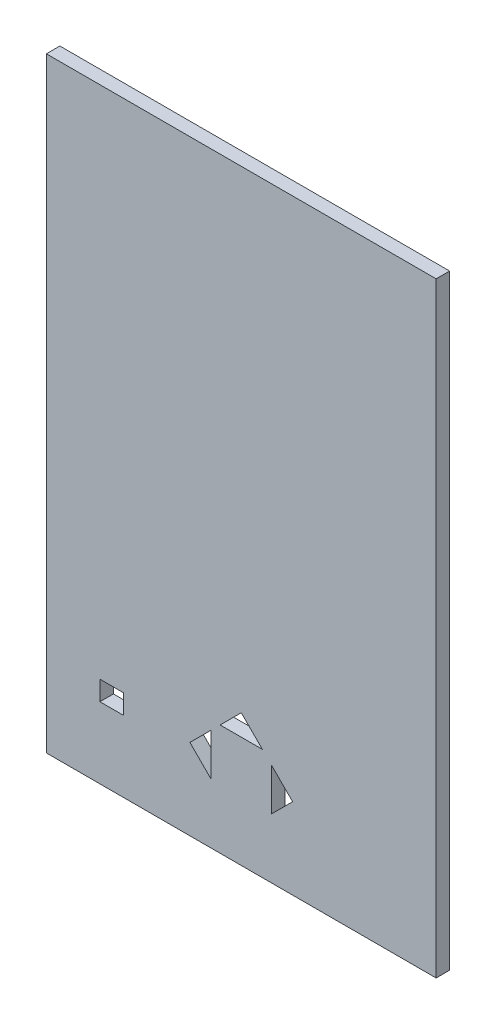
from build123d import *

# Parameters (mm, degrees)
SKETCH1_W           = 183.525
SKETCH1_H           = 285.125
BOSS_EXTRUDE1_DEPTH = 6.35
SKETCH2_W           = 11.200000206
SKETCH2_H           = 9.200000142
CUT_EXTRUDE1_DEPTH  = 7.35


with BuildPart() as part:
    # Sketch1 → Boss-Extrude1 (new body)
    with BuildSketch(Plane.XY):
        Rectangle(SKETCH1_W, SKETCH1_H)
    extrude(amount=-BOSS_EXTRUDE1_DEPTH)

    # Sketch2 → Cut-Extrude1 (cut, through all)
    with BuildSketch(Plane.XY):
        Polygon((24.182851904, -104.4625), (14.236910358, -94.516558454), (14.236910358, -114.408441546), align=None)
        Polygon((0, -80.279648096), (-9.945941546, -90.225589642), (9.945941546, -90.225589642), align=None)
        Polygon((-24.182851904, -104.4625), (-14.236910358, -114.408441546), (-14.236910358, -94.516558454), align=None)
        with Locations((-60.96, -104.4625)):
            Rectangle(SKETCH2_W, SKETCH2_H)
    extrude(amount=-CUT_EXTRUDE1_DEPTH, mode=Mode.SUBTRACT)


solid = part.part
